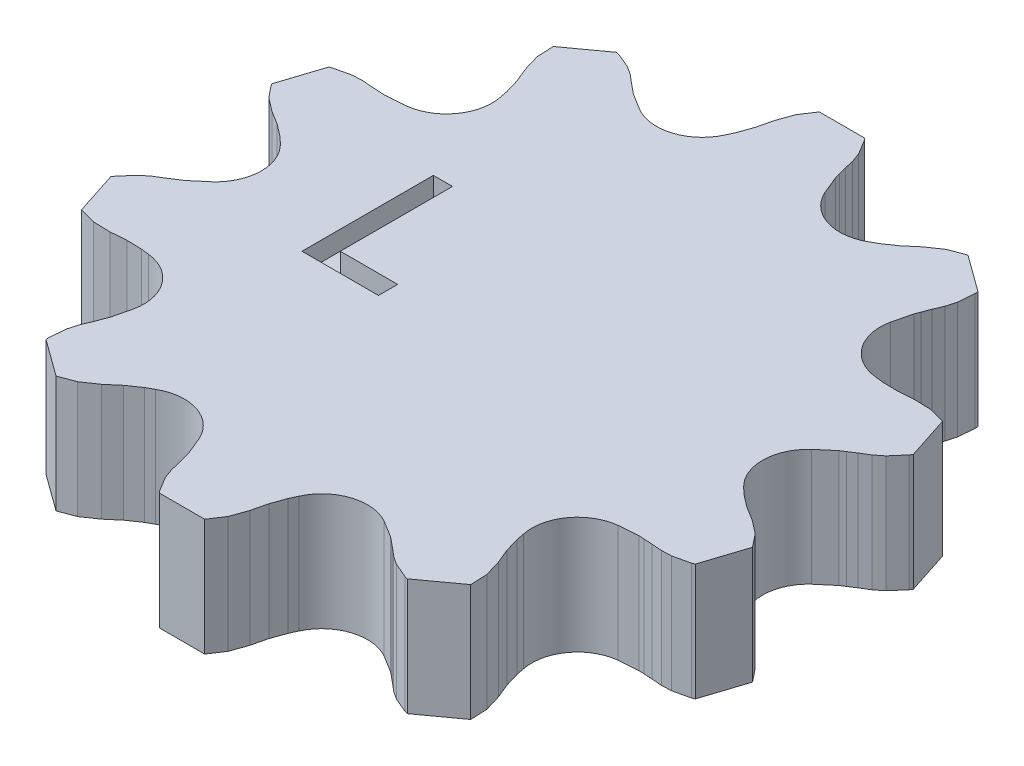
from build123d import *

# Parameters (mm, degrees)
BOSS_EXTRUDE1_DEPTH = 6.1
CUT_EXTRUDE1_DEPTH  = 1


with BuildPart() as part:
    # Sketch1 → Boss-Extrude1 (new body)
    with BuildSketch(Plane(origin=(0, 0, 0), x_dir=(1, 0, 0), z_dir=(0, 1, 0))):
        with BuildLine():
            ThreePointArc((-2.603734293, 13.735096717), (-4.043681259, 12.445171239), (-5.966821997, 12.642363282))
            Line((-5.966821997, 12.642363282), (-6.843279813, 13.183422247))
            Line((-6.843279813, 13.183422247), (-7.052164592, 13.353548445))
            Line((-7.052164592, 13.353548445), (-7.399861002, 13.637560961))
            Line((-7.399861002, 13.637560961), (-7.793732744, 13.973879308))
            Line((-7.793732744, 13.973879308), (-8.226942264, 14.264456075))
            Line((-8.226942264, 14.264456075), (-9.020650473, 14.599698524))
            Line((-9.020650473, 14.599698524), (-9.172029908, 14.639881345))
            Line((-9.172029908, 14.639881345), (-11.091125587, 13.245576719))
            Line((-11.091125587, 13.245576719), (-11.051137643, 12.366770586))
            Line((-11.051137643, 12.366770586), (-10.799290258, 11.512249619))
            Line((-10.799290258, 11.512249619), (-10.485832024, 10.75420757))
            Line((-10.485832024, 10.75420757), (-10.259959226, 9.993083115))
            Line((-10.259959226, 9.993083115), (-10.179752581, 9.581490045))
            ThreePointArc((-10.179752581, 9.581490045), (-10.586494975, 7.691538822), (-12.258255089, 6.720676771))
            Line((-12.258255089, 6.720676771), (-13.285350838, 6.643233691))
            Line((-13.285350838, 6.643233691), (-13.554339843, 6.658089283))
            Line((-13.554339843, 6.658089283), (-14.002570517, 6.683489414))
            Line((-14.002570517, 6.683489414), (-14.518902414, 6.72406467))
            Line((-14.518902414, 6.72406467), (-15.040173016, 6.704512046))
            Line((-15.040173016, 6.704512046), (-15.879347013, 6.509198904))
            Line((-15.879347013, 6.509198904), (-16.025434419, 6.452728891))
            Line((-16.025434419, 6.452728891), (-16.75846374, 4.196696614))
            Line((-16.75846374, 4.196696614), (-16.20956353, 3.509231842))
            Line((-16.20956353, 3.509231842), (-15.503539893, 2.965942036))
            Line((-15.503539893, 2.965942036), (-14.804380918, 2.536919263))
            Line((-14.804380918, 2.536919263), (-14.174268255, 2.053921344))
            Line((-14.174268255, 2.053921344), (-13.86745138, 1.768079839))
            ThreePointArc((-13.86745138, 1.768079839), (-13.085627432, 0), (-13.86745138, -1.768079839))
            Line((-13.86745138, -1.768079839), (-14.652869395, -2.434444341))
            Line((-14.652869395, -2.434444341), (-14.87921797, -2.580533684))
            Line((-14.87921797, -2.580533684), (-15.256774024, -2.823447927))
            Line((-15.256774024, -2.823447927), (-15.698344841, -3.094114129))
            Line((-15.698344841, -3.094114129), (-16.108568873, -3.416327706))
            Line((-16.108568873, -3.416327706), (-16.672672713, -4.067593457))
            Line((-16.672672713, -4.067593457), (-16.757667666, -4.19914668))
            Line((-16.757667666, -4.19914668), (-16.024638344, -6.455178957))
            Line((-16.024638344, -6.455178957), (-15.176487091, -6.688714191))
            Line((-15.176487091, -6.688714191), (-14.285964235, -6.713254596))
            Line((-14.285964235, -6.713254596), (-13.468159483, -6.649385976))
            Line((-13.468159483, -6.649385976), (-12.674488577, -6.66976857))
            Line((-12.674488577, -6.66976857), (-12.258255089, -6.720676771))
            ThreePointArc((-12.258255089, -6.720676771), (-10.586494975, -7.691538822), (-10.179752581, -9.581490045))
            Line((-10.179752581, -9.581490045), (-10.423489876, -10.582247377))
            Line((-10.423489876, -10.582247377), (-10.520740558, -10.833480493))
            Line((-10.520740558, -10.833480493), (-10.683408413, -11.251924125))
            Line((-10.683408413, -11.251924125), (-10.881553106, -11.730446496))
            Line((-10.881553106, -11.730446496), (-11.02403893, -12.232246392))
            Line((-11.02403893, -12.232246392), (-11.09760412, -13.09070337))
            Line((-11.09760412, -13.09070337), (-11.089041437, -13.247090943))
            Line((-11.089041437, -13.247090943), (-9.169945757, -14.641395569))
            Line((-9.169945757, -14.641395569), (-8.346508413, -14.331798745))
            Line((-8.346508413, -14.331798745), (-7.611635801, -13.828216148))
            Line((-7.611635801, -13.828216148), (-6.987558891, -13.295851776))
            Line((-6.987558891, -13.295851776), (-6.333485052, -12.845833588))
            Line((-6.333485052, -12.845833588), (-5.966821997, -12.642363282))
            ThreePointArc((-5.966821997, -12.642363282), (-4.043681259, -12.445171239), (-2.603734293, -13.735096717))
            Line((-2.603734293, -13.735096717), (-2.212691506, -14.687991594))
            Line((-2.212691506, -14.687991594), (-2.14369784, -14.94840597))
            Line((-2.14369784, -14.94840597), (-2.029343904, -15.382547746))
            Line((-2.029343904, -15.382547746), (-1.908377935, -15.886147005))
            Line((-1.908377935, -15.886147005), (-1.72870081, -16.375862714))
            Line((-1.72870081, -16.375862714), (-1.283627947, -17.113609532))
            Line((-1.283627947, -17.113609532), (-1.184778282, -17.235096718))
            Line((-1.184778282, -17.235096718), (1.187354434, -17.235096718))
            Line((1.187354434, -17.235096718), (1.671552791, -16.500623298))
            Line((1.671552791, -16.500623298), (1.970078799, -15.661269135))
            Line((1.970078799, -15.661269135), (2.162051698, -14.863754107))
            Line((2.162051698, -14.863754107), (2.426694495, -14.115226788))
            Line((2.426694495, -14.115226788), (2.603734293, -13.735096717))
            ThreePointArc((2.603734293, -13.735096717), (4.043681259, -12.445171239), (5.966821997, -12.642363282))
            Line((5.966821997, -12.642363282), (6.843279813, -13.183422247))
            Line((6.843279813, -13.183422247), (7.052164592, -13.353548445))
            Line((7.052164592, -13.353548445), (7.399861002, -13.637560961))
            Line((7.399861002, -13.637560961), (7.793732744, -13.973879308))
            Line((7.793732744, -13.973879308), (8.226942264, -14.264456075))
            Line((8.226942264, -14.264456075), (9.020650473, -14.599698524))
            Line((9.020650473, -14.599698524), (9.172029908, -14.639881345))
            Line((9.172029908, -14.639881345), (11.091125587, -13.245576719))
            Line((11.091125587, -13.245576719), (11.051137643, -12.366770586))
            Line((11.051137643, -12.366770586), (10.799290258, -11.512249619))
            Line((10.799290258, -11.512249619), (10.485832024, -10.75420757))
            Line((10.485832024, -10.75420757), (10.259959226, -9.993083115))
            Line((10.259959226, -9.993083115), (10.179752581, -9.581490045))
            ThreePointArc((10.179752581, -9.581490045), (10.586494975, -7.691538822), (12.258255089, -6.720676771))
            Line((12.258255089, -6.720676771), (13.285350838, -6.643233691))
            Line((13.285350838, -6.643233691), (13.554339843, -6.658089283))
            Line((13.554339843, -6.658089283), (14.002570517, -6.683489414))
            Line((14.002570517, -6.683489414), (14.518902414, -6.72406467))
            Line((14.518902414, -6.72406467), (15.040173016, -6.704512046))
            Line((15.040173016, -6.704512046), (15.879347013, -6.509198904))
            Line((15.879347013, -6.509198904), (16.025434419, -6.452728891))
            Line((16.025434419, -6.452728891), (16.75846374, -4.196696614))
            Line((16.75846374, -4.196696614), (16.20956353, -3.509231842))
            Line((16.20956353, -3.509231842), (15.503539893, -2.965942036))
            Line((15.503539893, -2.965942036), (14.804380918, -2.536919263))
            Line((14.804380918, -2.536919263), (14.174268255, -2.053921344))
            Line((14.174268255, -2.053921344), (13.86745138, -1.768079839))
            ThreePointArc((13.86745138, -1.768079839), (13.085627432, 0), (13.86745138, 1.768079839))
            Line((13.86745138, 1.768079839), (14.652869395, 2.434444341))
            Line((14.652869395, 2.434444341), (14.87921797, 2.580533684))
            Line((14.87921797, 2.580533684), (15.256774024, 2.823447927))
            Line((15.256774024, 2.823447927), (15.698344841, 3.094114129))
            Line((15.698344841, 3.094114129), (16.108568873, 3.416327706))
            Line((16.108568873, 3.416327706), (16.672672713, 4.067593457))
            Line((16.672672713, 4.067593457), (16.757667666, 4.19914668))
            Line((16.757667666, 4.19914668), (16.024638344, 6.455178957))
            Line((16.024638344, 6.455178957), (15.176487091, 6.688714191))
            Line((15.176487091, 6.688714191), (14.285964235, 6.713254596))
            Line((14.285964235, 6.713254596), (13.468159483, 6.649385976))
            Line((13.468159483, 6.649385976), (12.674488577, 6.66976857))
            Line((12.674488577, 6.66976857), (12.258255089, 6.720676771))
            ThreePointArc((12.258255089, 6.720676771), (10.586494975, 7.691538822), (10.179752581, 9.581490045))
            Line((10.179752581, 9.581490045), (10.423489876, 10.582247377))
            Line((10.423489876, 10.582247377), (10.520740558, 10.833480493))
            Line((10.520740558, 10.833480493), (10.683408413, 11.251924125))
            Line((10.683408413, 11.251924125), (10.881553106, 11.730446496))
            Line((10.881553106, 11.730446496), (11.02403893, 12.232246392))
            Line((11.02403893, 12.232246392), (11.09760412, 13.09070337))
            Line((11.09760412, 13.09070337), (11.089041437, 13.247090943))
            Line((11.089041437, 13.247090943), (9.169945757, 14.641395569))
            Line((9.169945757, 14.641395569), (8.346508413, 14.331798745))
            Line((8.346508413, 14.331798745), (7.611635801, 13.828216148))
            Line((7.611635801, 13.828216148), (6.987558891, 13.295851776))
            Line((6.987558891, 13.295851776), (6.333485052, 12.845833588))
            Line((6.333485052, 12.845833588), (5.966821997, 12.642363282))
            ThreePointArc((5.966821997, 12.642363282), (4.043681259, 12.445171239), (2.603734293, 13.735096717))
            Line((2.603734293, 13.735096717), (2.212691506, 14.687991594))
            Line((2.212691506, 14.687991594), (2.14369784, 14.94840597))
            Line((2.14369784, 14.94840597), (2.029343904, 15.382547746))
            Line((2.029343904, 15.382547746), (1.908377935, 15.886147005))
            Line((1.908377935, 15.886147005), (1.72870081, 16.375862714))
            Line((1.72870081, 16.375862714), (1.283627947, 17.113609532))
            Line((1.283627947, 17.113609532), (1.184778282, 17.235096718))
            Line((1.184778282, 17.235096718), (-1.187354434, 17.235096718))
            Line((-1.187354434, 17.235096718), (-1.671552791, 16.500623298))
            Line((-1.671552791, 16.500623298), (-1.970078799, 15.661269135))
            Line((-1.970078799, 15.661269135), (-2.162051698, 14.863754107))
            Line((-2.162051698, 14.863754107), (-2.426694495, 14.115226788))
            Line((-2.426694495, 14.115226788), (-2.603734293, 13.735096717))
        make_face()
    extrude(amount=BOSS_EXTRUDE1_DEPTH)

    # Sketch3 → Cut-Extrude1 (cut)
    with BuildSketch(Plane(origin=(0, 6.1, 0), x_dir=(1, 0, 0), z_dir=(0, 1, 0))):
        Polygon((-8.393092124, 4.285361852), (-8.393092124, -2.575657901), (-4.396381589, -2.575657901), (-4.396381589, -1.575657901), (-7.393092124, -1.575657901), (-7.393092124, 4.285361852), align=None)
    extrude(amount=-CUT_EXTRUDE1_DEPTH, mode=Mode.SUBTRACT)


solid = part.part
